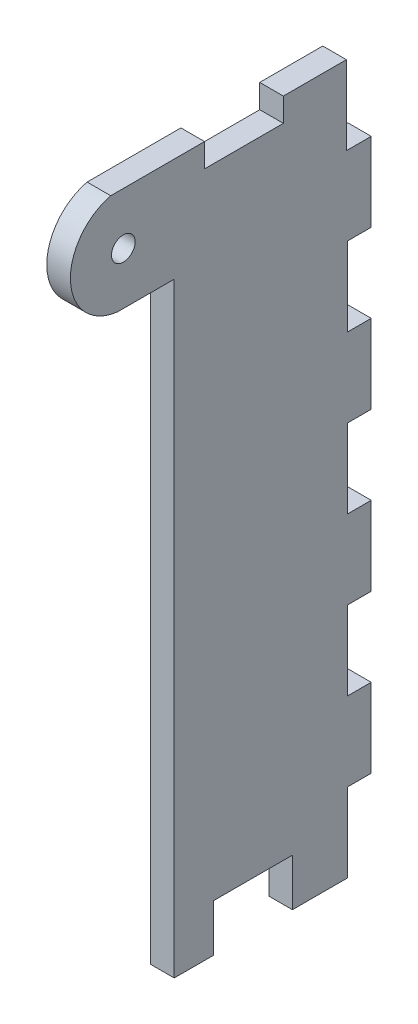
from build123d import *

# Parameters (mm, degrees)
SKETCH1_R           = 1.5
BOSS_EXTRUDE1_DEPTH = 3


with BuildPart() as part:
    # Sketch1 → Boss-Extrude1 (new body)
    with BuildSketch(Plane(origin=(0, 0, 0), x_dir=(0, 0, -1), z_dir=(1, 0, 0))):
        with BuildLine():
            Line((-9.38169605, 95.692985903), (-1.06418499, 95.692985903))
            Line((-1.06418499, 95.692985903), (2.525652309, 95.692985903))
            Line((2.525652309, 95.692985903), (2.525652309, 92.692985903))
            Line((2.525652309, 92.692985903), (12.525652309, 92.692985903))
            Line((12.525652309, 92.692985903), (12.525652309, 95.692985903))
            Line((12.525652309, 95.692985903), (20.525652309, 95.692985903))
            Line((20.525652309, 95.692985903), (20.525652309, 85.692985903))
            Line((20.525652309, 85.692985903), (23.675577753, 85.692985903))
            Line((23.675577753, 85.692985903), (23.675577753, 75.692985903))
            Line((23.675577753, 75.692985903), (20.675577753, 75.692985903))
            Line((20.675577753, 75.692985903), (20.675577753, 65.692985903))
            Line((20.675577753, 65.692985903), (23.675577753, 65.692985903))
            Line((23.675577753, 65.692985903), (23.675577753, 55.692985903))
            Line((23.675577753, 55.692985903), (20.675577753, 55.692985903))
            Line((20.675577753, 55.692985903), (20.675577753, 45.692985903))
            Line((20.675577753, 45.692985903), (23.675577753, 45.692985903))
            Line((23.675577753, 45.692985903), (23.675577753, 35.692985903))
            Line((23.675577753, 35.692985903), (20.675577753, 35.692985903))
            Line((20.675577753, 35.692985903), (20.675577753, 25.692985903))
            Line((20.675577753, 25.692985903), (23.675577753, 25.692985903))
            Line((23.675577753, 25.692985903), (23.675577753, 15.692985903))
            Line((23.675577753, 15.692985903), (20.675577753, 15.692985903))
            Line((20.675577753, 15.692985903), (20.675577753, 5.692985903))
            Line((20.675577753, 5.692985903), (13.675577753, 5.692985903))
            Line((13.675577753, 5.692985903), (13.675577753, 11.692985903))
            Line((13.675577753, 11.692985903), (3.675577753, 11.692985903))
            Line((3.675577753, 11.692985903), (3.675577753, 5.692985903))
            Line((3.675577753, 5.692985903), (-1.324422247, 5.692985903))
            Line((-1.324422247, 5.692985903), (-1.324422247, 82.492985903))
            Line((-1.324422247, 82.492985903), (-8.482000981, 82.492985903))
            ThreePointArc((-8.482000981, 82.492985903), (-14.479905975, 88.714837423), (-9.38169605, 95.692985903))
        make_face()
        with Locations((-7.783554384, 89.092985903)):
            Circle(SKETCH1_R, mode=Mode.SUBTRACT)
    extrude(amount=BOSS_EXTRUDE1_DEPTH)


solid = part.part
